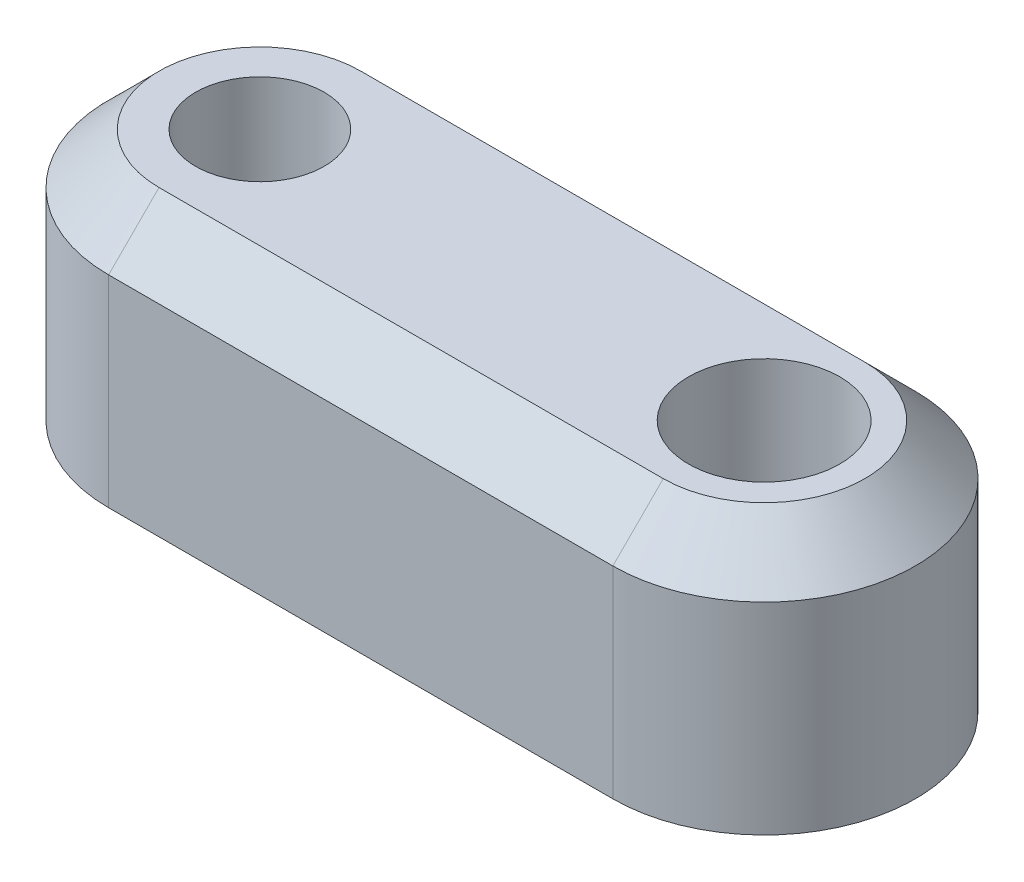
from build123d import *

# Parameters (mm, degrees)
EXTRUDE_1_DEPTH = 10
CHAMFER_1_SIZE  = 2


with BuildPart() as part:
    # 草图1 → 凸台-拉伸1 (new body)
    with BuildSketch(Plane(origin=(0, 0, 0), x_dir=(1, 0, 0), z_dir=(0, 1, 0))):
        with BuildLine():
            Line((0, 6), (20, 6))
            ThreePointArc((20, 6), (26, 0), (20, -6))
            Line((20, -6), (0, -6))
            ThreePointArc((0, -6), (-6, 0), (0, 6))
        make_face()
    extrude(amount=EXTRUDE_1_DEPTH)

    # 草图2 → 切除-旋转1 (revolve, cut)
    with BuildSketch(Plane.XY):
        Polygon((0, 10), (-2.55, 10), (-2.55, 5), (-1.6, 5), (-1.6, 2), (-2.55, 2), (-2.55, 0), (0, 0), align=None)
    revolve(axis=Axis((0, 0, 0), (0, 1, 0)), mode=Mode.SUBTRACT)

    # 草图4 → 切除-旋转2 (revolve, cut)
    with BuildSketch(Plane.XY):
        Polygon((20, 10), (17, 10), (17, 5), (17.425, 5), (17.425, 0), (20, 0), align=None)
    revolve(axis=Axis((20, 0, 0), (0, 1, 0)), mode=Mode.SUBTRACT)

    # 倒角1
    chamfer_1_edges = [part.edges().sort_by_distance(p)[0] for p in [
        (26, 10, 0),
        (10, 10, -6),
        (-6, 10, 0),
        (10, 10, 6),
    ]]
    chamfer(chamfer_1_edges, length=CHAMFER_1_SIZE)


solid = part.part
